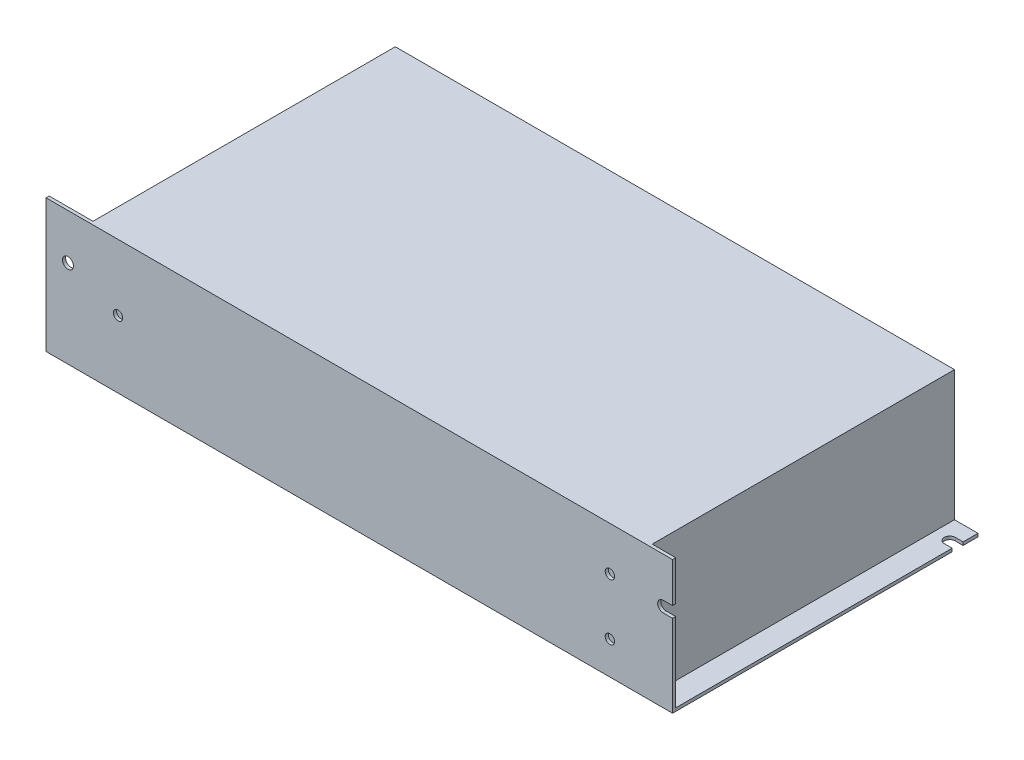
from build123d import *

# Parameters (mm, degrees)
SKETCH1_R           = 1.5
BOSS_EXTRUDE1_DEPTH = 42.5
SKETCH2_W           = 7.5
SKETCH2_H           = 96.5
SKETCH2_W_2         = 14
CUT_EXTRUDE1_DEPTH  = 41.5
CUT_EXTRUDE2_REACH  = 99.5
SKETCH3_R           = 1.75
SKETCH4_W           = 14
SKETCH4_H           = 75
BOSS_EXTRUDE2_DEPTH = 23
SKETCH5_R           = 1.5
CUT_EXTRUDE3_DEPTH  = 1
SKETCH6_R           = 1.5
CUT_EXTRUDE4_DEPTH  = 1


with BuildPart() as part:
    # Sketch1 → Boss-Extrude1 (new body)
    with BuildSketch(Plane(origin=(0, 0, 0), x_dir=(1, 0, 0), z_dir=(0, 1, 0))):
        with BuildLine():
            Line((197.5, 92.75), (200, 92.75))
            Line((200, 92.75), (200, 97.5))
            Line((200, 97.5), (0, 97.5))
            Line((0, 97.5), (0, 0))
            Line((0, 0), (200, 0))
            Line((200, 0), (200, 89.25))
            Line((200, 89.25), (197.5, 89.25))
            ThreePointArc((197.5, 89.25), (195.75, 91), (197.5, 92.75))
        make_face()
        with Locations((3, 7.5)):
            Circle(SKETCH1_R, mode=Mode.SUBTRACT)
    extrude(amount=BOSS_EXTRUDE1_DEPTH)

    # Sketch2 → Cut-Extrude1 (cut)
    with BuildSketch(Plane(origin=(0, 42.5, 0), x_dir=(1, 0, 0), z_dir=(0, 1, 0))):
        with Locations((196.25, 49.25)):
            Rectangle(SKETCH2_W, SKETCH2_H)
        with Locations((7, 49.25)):
            Rectangle(SKETCH2_W_2, SKETCH2_H)
    extrude(amount=-CUT_EXTRUDE1_DEPTH, mode=Mode.SUBTRACT)

    # Sketch3 → Cut-Extrude2 (cut, up to next)
    with BuildSketch(Plane.XY, mode=Mode.PRIVATE) as cut_extrude2_sk1:
        with Locations((7, 28)):
            Circle(SKETCH3_R)
    cut_extrude2_tool1 = extrude(cut_extrude2_sk1.sketch, amount=-CUT_EXTRUDE2_REACH, mode=Mode.PRIVATE) & part.part
    add(cut_extrude2_tool1.solids().sort_by_distance((7, 28, 0))[0], mode=Mode.SUBTRACT)
    # Sketch3 → Cut-Extrude2 (cut, up to next)
    with BuildSketch(Plane.XY, mode=Mode.PRIVATE) as cut_extrude2_sk2:
        with BuildLine():
            Line((197, 29.75), (200, 29.75))
            Line((200, 29.75), (200, 26.25))
            Line((200, 26.25), (197, 26.25))
            ThreePointArc((197, 26.25), (195.25, 28), (197, 29.75))
        make_face()
    cut_extrude2_tool2 = extrude(cut_extrude2_sk2.sketch, amount=-CUT_EXTRUDE2_REACH, mode=Mode.PRIVATE) & part.part
    add(cut_extrude2_tool2.solids().sort_by_distance((197.795339, 28, 0))[0], mode=Mode.SUBTRACT)

    # Sketch4 → Boss-Extrude2 (add)
    with BuildSketch(Plane(origin=(0, 1, 0), x_dir=(1, 0, 0), z_dir=(0, 1, 0))):
        with Locations((7, 50)):
            Rectangle(SKETCH4_W, SKETCH4_H)
    extrude(amount=BOSS_EXTRUDE2_DEPTH)

    # Sketch5 → Cut-Extrude3 (cut)
    with BuildSketch(Plane.XY):
        with Locations((23, 21.5)):
            Circle(SKETCH5_R)
        with Locations((180, 10.5)):
            Circle(SKETCH5_R)
        with Locations((180, 28.5)):
            Circle(SKETCH5_R)
    extrude(amount=-CUT_EXTRUDE3_DEPTH, mode=Mode.SUBTRACT)

    # Sketch6 → Cut-Extrude4 (cut)
    with BuildSketch(Plane.XZ):
        with Locations((5, -92.5)):
            Circle(SKETCH6_R)
        with Locations((60, -9.5)):
            Circle(SKETCH6_R)
        with Locations((60, -89.5)):
            Circle(SKETCH6_R)
        with Locations((180, -89.5)):
            Circle(SKETCH6_R)
        with Locations((180, -9.5)):
            Circle(SKETCH6_R)
        with Locations((172.5, -92.5)):
            Circle(SKETCH6_R)
    extrude(amount=-CUT_EXTRUDE4_DEPTH, mode=Mode.SUBTRACT)


solid = part.part
